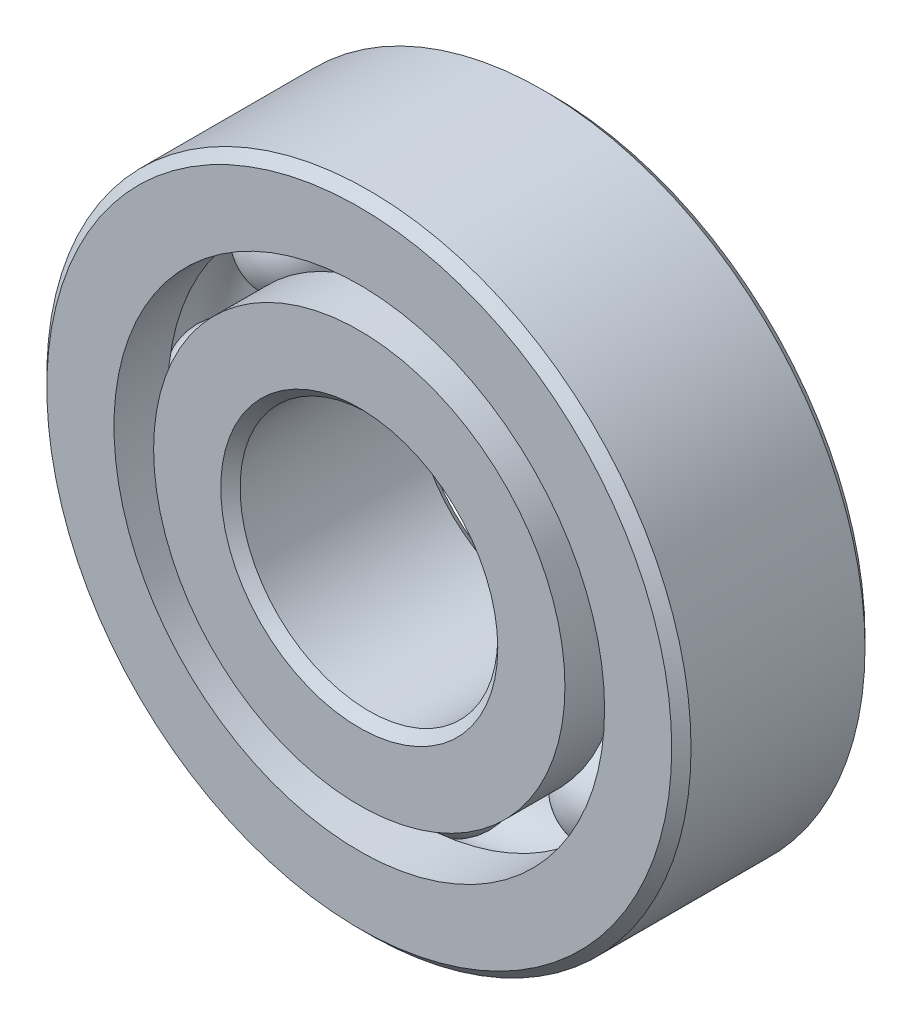
from build123d import *

# Parameters (mm, degrees)
CIRPATTERN1_COUNT = 8


with BuildPart() as part:
    # Sketch1 → Revolve1 (revolve)
    with BuildSketch(Plane(origin=(0, 0, 0), x_dir=(0, 0, -1), z_dir=(1, 0, 0))):
        with BuildLine():
            Line((2.143125, 7.9375), (-2.143125, 7.9375))
            Line((-2.143125, 7.9375), (-2.38125, 7.699375))
            Line((-2.38125, 7.699375), (-2.38125, 6.044711538))
            Line((-2.38125, 6.044711538), (-1.058333333, 6.044711538))
            ThreePointArc((-1.058333333, 6.044711538), (0, 6.721867484), (1.058333333, 6.044711538))
            Line((1.058333333, 6.044711538), (2.38125, 6.044711538))
            Line((2.38125, 6.044711538), (2.38125, 7.699375))
            Line((2.38125, 7.699375), (2.143125, 7.9375))
        make_face()
    revolve(axis=Axis((0, 0, 2.38125), (0, 0, -1)))


with BuildPart() as body_2:
    # Sketch3 → Revolve3 (revolve)
    with BuildSketch(Plane(origin=(0, 0, 0), x_dir=(0, 0, -1), z_dir=(1, 0, 0))):
        with BuildLine():
            Line((-2.38125, 5.067788462), (-1.058333333, 5.067788462))
            ThreePointArc((-1.058333333, 5.067788462), (0, 4.390632516), (1.058333333, 5.067788462))
            Line((1.058333333, 5.067788462), (2.38125, 5.067788462))
            Line((2.38125, 5.067788462), (2.38125, 3.413125))
            Line((2.38125, 3.413125), (2.143125, 3.175))
            Line((2.143125, 3.175), (-2.143125, 3.175))
            Line((-2.143125, 3.175), (-2.38125, 3.413125))
            Line((-2.38125, 3.413125), (-2.38125, 5.067788462))
        make_face()
    revolve(axis=Axis((0, 0, 2.38125), (0, 0, -1)))


with BuildPart() as body_3:
    # Sketch4 → Revolve4 (revolve)
    with BuildSketch(Plane(origin=(0, 0, 0), x_dir=(0, 0, -1), z_dir=(1, 0, 0))):
        with BuildLine():
            Line((-1.165617484, 5.55625), (1.165617484, 5.55625))
            ThreePointArc((1.165617484, 5.55625), (0, 6.721867484), (-1.165617484, 5.55625))
        make_face()
    revolve(axis=Axis((0, 5.55625, 1.165617484), (0, 0, -1)))


with BuildPart() as cirpattern1_1:
    # CirPattern1: pattern copy
    add(body_3.part.rotate(Axis((0, 0, 0), (0, 0, 1)), 1 * 360 / CIRPATTERN1_COUNT))


with BuildPart() as cirpattern1_2:
    # CirPattern1: pattern copy
    add(body_3.part.rotate(Axis((0, 0, 0), (0, 0, 1)), 2 * 360 / CIRPATTERN1_COUNT))


with BuildPart() as cirpattern1_3:
    # CirPattern1: pattern copy
    add(body_3.part.rotate(Axis((0, 0, 0), (0, 0, 1)), 3 * 360 / CIRPATTERN1_COUNT))


with BuildPart() as cirpattern1_4:
    # CirPattern1: pattern copy
    add(body_3.part.rotate(Axis((0, 0, 0), (0, 0, 1)), 4 * 360 / CIRPATTERN1_COUNT))


with BuildPart() as cirpattern1_5:
    # CirPattern1: pattern copy
    add(body_3.part.rotate(Axis((0, 0, 0), (0, 0, 1)), 5 * 360 / CIRPATTERN1_COUNT))


with BuildPart() as cirpattern1_6:
    # CirPattern1: pattern copy
    add(body_3.part.rotate(Axis((0, 0, 0), (0, 0, 1)), 6 * 360 / CIRPATTERN1_COUNT))


with BuildPart() as cirpattern1_7:
    # CirPattern1: pattern copy
    add(body_3.part.rotate(Axis((0, 0, 0), (0, 0, 1)), 7 * 360 / CIRPATTERN1_COUNT))


solid = Compound([part.part, body_2.part, body_3.part, cirpattern1_1.part, cirpattern1_2.part, cirpattern1_3.part, cirpattern1_4.part, cirpattern1_5.part, cirpattern1_6.part, cirpattern1_7.part])
